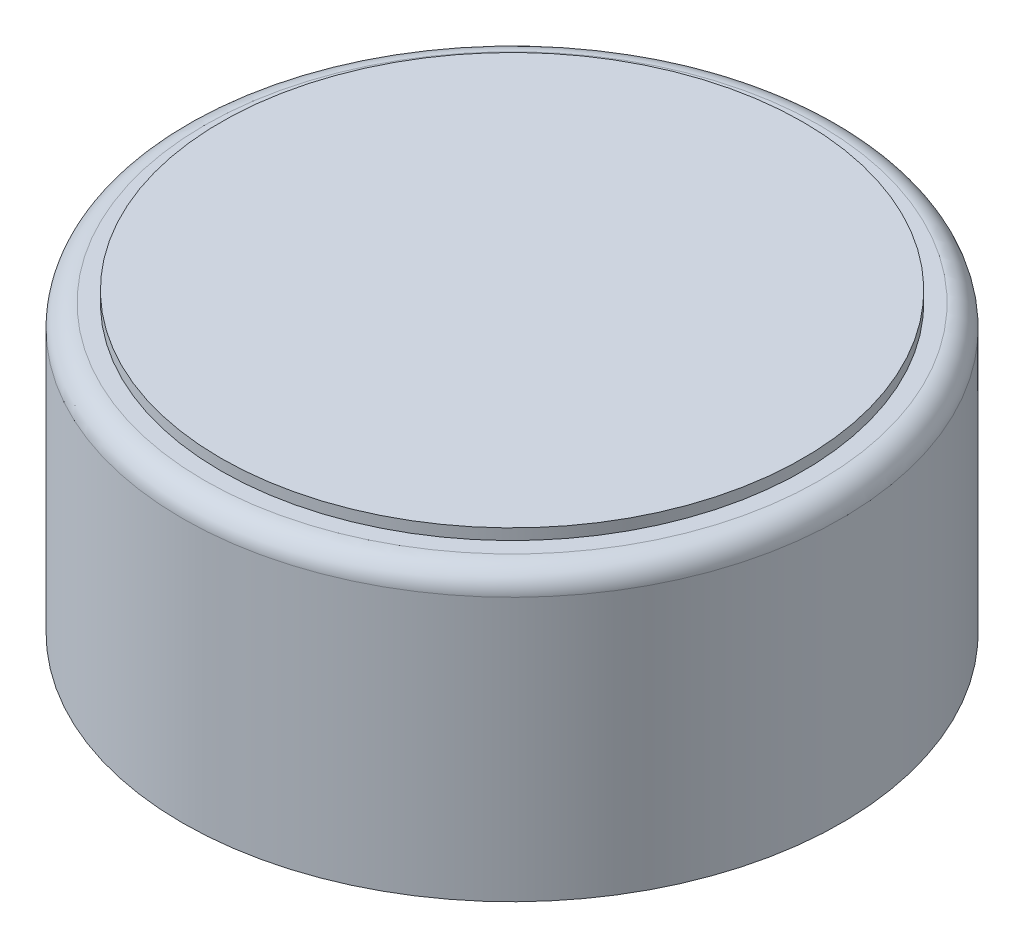
from build123d import *

# Parameters (mm, degrees)
SKETCH1_R           = 3
BOSS_EXTRUDE1_DEPTH = 2.6
FILLET1_R           = 0.2
SKETCH2_R           = 2.65
BOSS_EXTRUDE2_DEPTH = 0.1
SKETCH3_R           = 0.2
SKETCH3_R_2         = 0.25
BOSS_EXTRUDE3_DEPTH = 1


with BuildPart() as part:
    # Sketch1 → Boss-Extrude1 (new body)
    with BuildSketch(Plane(origin=(0, 0, 0), x_dir=(1, 0, 0), z_dir=(0, 1, 0))):
        Circle(SKETCH1_R)
    extrude(amount=BOSS_EXTRUDE1_DEPTH)

    # Fillet1
    fillet1_edges = [part.edges().sort_by_distance(p)[0] for p in [
        (-3, 2.6, 0),
    ]]
    fillet(fillet1_edges, radius=FILLET1_R)

    # Sketch2 → Boss-Extrude2 (add)
    with BuildSketch(Plane(origin=(0, 2.6, 0), x_dir=(1, 0, 0), z_dir=(0, 1, 0))):
        Circle(SKETCH2_R)
    extrude(amount=BOSS_EXTRUDE2_DEPTH)

    # Sketch3 → Boss-Extrude3 (add)
    with BuildSketch(Plane.XZ):
        with Locations((-1.27, 1.27)):
            Circle(SKETCH3_R)
        with Locations((-1.27, -1.27)):
            Circle(SKETCH3_R_2)
    extrude(amount=BOSS_EXTRUDE3_DEPTH)


solid = part.part
